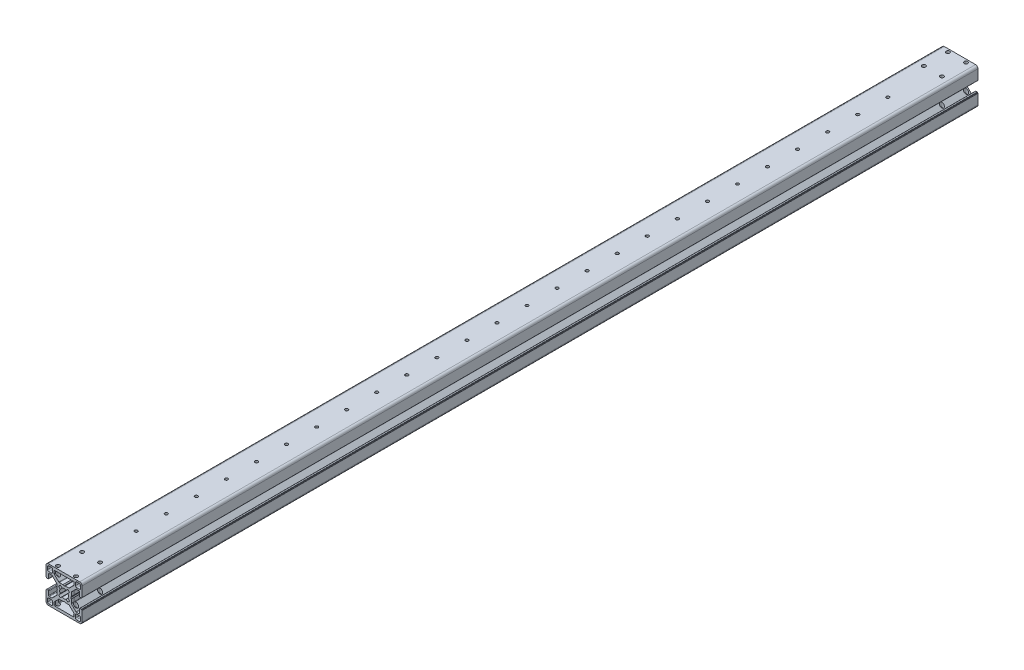
from build123d import *

# Parameters (mm, degrees)
AUFSATZ_LINEAR_AUSTRAGEN1_DEPTH = 745
LINEARES_MUSTER1_COUNT          = 14
LINEARES_MUSTER1_PITCH          = 25
LINEARES_MUSTER1_COL_COUNT      = 13
LINEARES_MUSTER1_COL_PITCH      = 25
F_3_0_3_DURCHMESSER_BOHRUNG1_D  = 3


with BuildPart() as part:
    # Skizze1 → Aufsatz-Linear austragen1 (new body)
    with BuildSketch(Plane.XY.offset(1000)):
        with BuildLine():
            Line((0, -30), (26.000000692, -30))
            ThreePointArc((26.000000692, -30), (27.41421401, -29.414213664), (28.000000346, -28.000000346))
            Line((28.000000346, -28.000000346), (28.000000346, -19.699999564))
            ThreePointArc((28.000000346, -19.699999564), (27.941421702, -19.558578208), (27.800000346, -19.499999564))
            Line((27.800000346, -19.499999564), (27.500000346, -19.499999564))
            Line((27.500000346, -19.499999564), (27.500000346, -19.200000374))
            ThreePointArc((27.500000346, -19.200000374), (27.441421593, -19.058578753), (27.299999973, -19))
            Line((27.299999973, -19), (26.29999991, -19))
            ThreePointArc((26.29999991, -19), (25.94644652, -19.146446609), (25.79999991, -19.5))
            Line((25.79999991, -19.5), (25.79999991, -22.75))
            ThreePointArc((25.79999991, -22.75), (25.653553301, -23.103553391), (25.29999991, -23.25))
            Line((25.29999991, -23.25), (23.257106692, -23.25))
            ThreePointArc((23.257106692, -23.25), (23.065764975, -23.211939766), (22.903553301, -23.103553391))
            Line((22.903553301, -23.103553391), (19.150912386, -19.350912475))
            ThreePointArc((19.150912386, -19.350912475), (19.04252601, -19.188700801), (19.004465776, -18.997359085))
            Line((19.004465776, -18.997359085), (19.004465776, -15.9535893))
            ThreePointArc((19.004465776, -15.9535893), (18.99765098, -15.901825632), (18.977671004, -15.853589554))
            Line((18.977671004, -15.853589554), (18.542587196, -15.099999747))
            ThreePointArc((18.542587196, -15.099999747), (18.515792423, -15), (18.542587196, -14.900000253))
            Line((18.542587196, -14.900000253), (18.977671004, -14.146410446))
            ThreePointArc((18.977671004, -14.146410446), (18.99765098, -14.098174367), (19.004465776, -14.0464107))
            Line((19.004465776, -14.0464107), (19.004465776, -11.002640915))
            ThreePointArc((19.004465776, -11.002640915), (19.04252601, -10.811299199), (19.150912386, -10.649087524))
            Line((19.150912386, -10.649087524), (22.903553301, -6.896446609))
            ThreePointArc((22.903553301, -6.896446609), (23.065764975, -6.788060234), (23.257106692, -6.75))
            Line((23.257106692, -6.75), (25.29999991, -6.75))
            ThreePointArc((25.29999991, -6.75), (25.653553301, -6.896446609), (25.79999991, -7.25))
            Line((25.79999991, -7.25), (25.79999991, -10.5))
            ThreePointArc((25.79999991, -10.5), (25.94644652, -10.853553391), (26.29999991, -11))
            Line((26.29999991, -11), (27.299999973, -11))
            ThreePointArc((27.299999973, -11), (27.441421593, -10.941421247), (27.500000346, -10.799999626))
            Line((27.500000346, -10.799999626), (27.500000346, -10.500000436))
            Line((27.500000346, -10.500000436), (27.800000346, -10.500000436))
            ThreePointArc((27.800000346, -10.500000436), (27.941421702, -10.441421792), (28.000000346, -10.300000436))
            Line((28.000000346, -10.300000436), (28.000000346, -1.999999654))
            ThreePointArc((28.000000346, -1.999999654), (27.41421401, -0.585786336), (26.000000692, 0))
            Line((26.000000692, 0), (0, 0))
            ThreePointArc((0, 0), (-1.414213318, -0.585786336), (-1.999999654, -1.999999654))
            Line((-1.999999654, -1.999999654), (-1.999999654, -10.300000436))
            ThreePointArc((-1.999999654, -10.300000436), (-1.94142101, -10.441421792), (-1.799999654, -10.500000436))
            Line((-1.799999654, -10.500000436), (-1.499999654, -10.500000436))
            Line((-1.499999654, -10.500000436), (-1.499999654, -10.799999626))
            ThreePointArc((-1.499999654, -10.799999626), (-1.441420901, -10.941421247), (-1.29999928, -11))
            Line((-1.29999928, -11), (-0.299999218, -11))
            ThreePointArc((-0.299999218, -11), (0.053554173, -10.853553391), (0.200000782, -10.5))
            Line((0.200000782, -10.5), (0.200000782, -7.25))
            ThreePointArc((0.200000782, -7.25), (0.346447391, -6.896446609), (0.700000782, -6.75))
            Line((0.700000782, -6.75), (2.742894001, -6.75))
            ThreePointArc((2.742894001, -6.75), (2.934235717, -6.788060234), (3.096447391, -6.896446609))
            Line((3.096447391, -6.896446609), (6.849088307, -10.649087524))
            ThreePointArc((6.849088307, -10.649087524), (6.957474682, -10.811299199), (6.995534916, -11.002640915))
            Line((6.995534916, -11.002640915), (6.995534916, -14.0464107))
            ThreePointArc((6.995534916, -14.0464107), (7.002349713, -14.098174368), (7.022329689, -14.146410446))
            Line((7.022329689, -14.146410446), (7.457413497, -14.900000253))
            ThreePointArc((7.457413497, -14.900000253), (7.484208269, -15), (7.457413497, -15.099999747))
            Line((7.457413497, -15.099999747), (7.022329689, -15.853589554))
            ThreePointArc((7.022329689, -15.853589554), (7.002349713, -15.901825632), (6.995534916, -15.9535893))
            Line((6.995534916, -15.9535893), (6.995534916, -18.997359085))
            ThreePointArc((6.995534916, -18.997359085), (6.957474682, -19.188700801), (6.849088307, -19.350912475))
            Line((6.849088307, -19.350912475), (3.096447391, -23.103553391))
            ThreePointArc((3.096447391, -23.103553391), (2.934235717, -23.211939766), (2.742894001, -23.25))
            Line((2.742894001, -23.25), (0.700000782, -23.25))
            ThreePointArc((0.700000782, -23.25), (0.346447391, -23.103553391), (0.200000782, -22.75))
            Line((0.200000782, -22.75), (0.200000782, -19.5))
            ThreePointArc((0.200000782, -19.5), (0.053554173, -19.146446609), (-0.299999218, -19))
            Line((-0.299999218, -19), (-1.29999928, -19))
            ThreePointArc((-1.29999928, -19), (-1.441420901, -19.058578753), (-1.499999654, -19.200000374))
            Line((-1.499999654, -19.200000374), (-1.499999654, -19.499999564))
            Line((-1.499999654, -19.499999564), (-1.799999273, -19.499999564))
            ThreePointArc((-1.799999273, -19.499999564), (-1.941420898, -19.558578319), (-1.999999654, -19.699999945))
            Line((-1.999999654, -19.699999945), (-1.999999654, -28.000000346))
            ThreePointArc((-1.999999654, -28.000000346), (-1.414213318, -29.414213664), (0, -30))
        make_face()
        with BuildLine():
            Line((2.500000029, -5.500000365), (0.299999247, -5.500000365))
            ThreePointArc((0.299999247, -5.500000365), (-0.407107528, -5.207107148), (-0.700000744, -4.500000374))
            Line((-0.700000744, -4.500000374), (-0.700000744, -2.299999592))
            ThreePointArc((-0.700000744, -2.299999592), (-0.407107528, -1.592892818), (0.299999247, -1.299999602))
            Line((0.299999247, -1.299999602), (2.500000029, -1.299999602))
            ThreePointArc((2.500000029, -1.299999602), (3.207106803, -1.592892818), (3.500000019, -2.299999592))
            Line((3.500000019, -2.299999592), (3.500000019, -4.500000374))
            ThreePointArc((3.500000019, -4.500000374), (3.207106803, -5.207107148), (2.500000029, -5.500000365))
        make_face(mode=Mode.SUBTRACT)
        with BuildLine():
            Line((3.500000019, -25.499999626), (3.500000019, -27.700000408))
            ThreePointArc((3.500000019, -27.700000408), (3.207106803, -28.407107182), (2.500000029, -28.700000398))
            Line((2.500000029, -28.700000398), (0.299999247, -28.700000398))
            ThreePointArc((0.299999247, -28.700000398), (-0.407107528, -28.407107182), (-0.700000744, -27.700000408))
            Line((-0.700000744, -27.700000408), (-0.700000744, -25.499999626))
            ThreePointArc((-0.700000744, -25.499999626), (-0.407107528, -24.792892851), (0.299999247, -24.499999635))
            Line((0.299999247, -24.499999635), (2.500000029, -24.499999635))
            ThreePointArc((2.500000029, -24.499999635), (3.207106803, -24.792892851), (3.500000019, -25.499999626))
        make_face(mode=Mode.SUBTRACT)
        with BuildLine():
            Line((23.500000664, -24.499999635), (25.700001446, -24.499999635))
            ThreePointArc((25.700001446, -24.499999635), (26.40710822, -24.792892851), (26.700001436, -25.499999626))
            Line((26.700001436, -25.499999626), (26.700001436, -27.700000408))
            ThreePointArc((26.700001436, -27.700000408), (26.40710822, -28.407107182), (25.700001446, -28.700000398))
            Line((25.700001446, -28.700000398), (23.500000664, -28.700000398))
            ThreePointArc((23.500000664, -28.700000398), (22.792893889, -28.407107182), (22.500000673, -27.700000408))
            Line((22.500000673, -27.700000408), (22.500000673, -25.499999626))
            ThreePointArc((22.500000673, -25.499999626), (22.792893889, -24.792892851), (23.500000664, -24.499999635))
        make_face(mode=Mode.SUBTRACT)
        with BuildLine():
            Line((22.500000673, -4.500000374), (22.500000673, -2.299999592))
            ThreePointArc((22.500000673, -2.299999592), (22.792893889, -1.592892818), (23.500000664, -1.299999602))
            Line((23.500000664, -1.299999602), (25.700001446, -1.299999602))
            ThreePointArc((25.700001446, -1.299999602), (26.40710822, -1.592892818), (26.700001436, -2.299999592))
            Line((26.700001436, -2.299999592), (26.700001436, -4.500000374))
            ThreePointArc((26.700001436, -4.500000374), (26.40710822, -5.207107148), (25.700001446, -5.500000365))
            Line((25.700001446, -5.500000365), (23.500000664, -5.500000365))
            ThreePointArc((23.500000664, -5.500000365), (22.792893889, -5.207107148), (22.500000673, -4.500000374))
        make_face(mode=Mode.SUBTRACT)
        with BuildLine():
            Line((16.135929758, -19.518400903), (14.60012987, -18.280561767))
            ThreePointArc((14.60012987, -18.280561767), (13.000000346, -18.65), (11.399870822, -18.280561767))
            Line((11.399870822, -18.280561767), (9.864070934, -19.518400903))
            ThreePointArc((9.864070934, -19.518400903), (9.118998087, -18.897155561), (8.494663454, -18.154669473))
            Line((8.494663454, -18.154669473), (9.719438615, -16.600129596))
            ThreePointArc((9.719438615, -16.600129596), (9.350000346, -15), (9.719438615, -13.399870403))
            Line((9.719438615, -13.399870403), (8.494663454, -11.845330527))
            ThreePointArc((8.494663454, -11.845330527), (9.118998087, -11.102844439), (9.864070934, -10.481599097))
            Line((9.864070934, -10.481599097), (11.399870822, -11.719438233))
            ThreePointArc((11.399870822, -11.719438233), (13.000000346, -11.35), (14.60012987, -11.719438233))
            Line((14.60012987, -11.719438233), (16.135929758, -10.481599097))
            ThreePointArc((16.135929758, -10.481599097), (16.881002606, -11.102844439), (17.505337239, -11.845330527))
            Line((17.505337239, -11.845330527), (16.280562078, -13.399870403))
            ThreePointArc((16.280562078, -13.399870403), (16.650000346, -15), (16.280562078, -16.600129596))
            Line((16.280562078, -16.600129596), (17.505337239, -18.154669473))
            ThreePointArc((17.505337239, -18.154669473), (16.881002606, -18.89715556), (16.135929758, -19.518400903))
        make_face(mode=Mode.SUBTRACT)
        with BuildLine():
            Line((17.350946534, -21.146641666), (21.103749013, -24.903586157))
            ThreePointArc((21.103749013, -24.903586157), (21.211993189, -25.065730174), (21.250000673, -25.256944491))
            Line((21.250000673, -25.256944491), (21.250000673, -27.299999237))
            ThreePointArc((21.250000673, -27.299999237), (21.103554064, -27.653552628), (20.750000673, -27.799999237))
            Line((20.750000673, -27.799999237), (5.250000019, -27.799999237))
            ThreePointArc((5.250000019, -27.799999237), (4.896446629, -27.653552628), (4.750000019, -27.299999237))
            Line((4.750000019, -27.299999237), (4.750000019, -25.256944491))
            ThreePointArc((4.750000019, -25.256944491), (4.788007503, -25.065730174), (4.896251679, -24.903586157))
            Line((4.896251679, -24.903586157), (8.649054159, -21.146641666))
            ThreePointArc((8.649054159, -21.146641666), (8.811333398, -21.038113019), (9.002802498, -21))
            Line((9.002802498, -21), (12.046810201, -21))
            ThreePointArc((12.046810201, -21), (12.098213578, -20.993281383), (12.146163358, -20.973576929))
            Line((12.146163358, -20.973576929), (12.900647189, -20.541720281))
            ThreePointArc((12.900647189, -20.541720281), (13.000000346, -20.51529721), (13.099353503, -20.541720281))
            Line((13.099353503, -20.541720281), (13.853837334, -20.973576929))
            ThreePointArc((13.853837334, -20.973576929), (13.901787115, -20.993281383), (13.953190491, -21))
            Line((13.953190491, -21), (16.997198194, -21))
            ThreePointArc((16.997198194, -21), (17.188667295, -21.038113019), (17.350946534, -21.146641666))
        make_face(mode=Mode.SUBTRACT)
        with BuildLine():
            Line((16.997198194, -9), (13.953190491, -9))
            ThreePointArc((13.953190491, -9), (13.901787115, -9.006718617), (13.853837334, -9.026423071))
            Line((13.853837334, -9.026423071), (13.099353503, -9.458279719))
            ThreePointArc((13.099353503, -9.458279719), (13.000000346, -9.48470279), (12.900647189, -9.458279719))
            Line((12.900647189, -9.458279719), (12.146163358, -9.026423071))
            ThreePointArc((12.146163358, -9.026423071), (12.098213578, -9.006718617), (12.046810201, -9))
            Line((12.046810201, -9), (9.002802498, -9))
            ThreePointArc((9.002802498, -9), (8.811333398, -8.961886981), (8.649054159, -8.853358334))
            Line((8.649054159, -8.853358334), (4.896251679, -5.096413843))
            ThreePointArc((4.896251679, -5.096413843), (4.788007503, -4.934269826), (4.750000019, -4.743055509))
            Line((4.750000019, -4.743055509), (4.750000019, -2.700000763))
            ThreePointArc((4.750000019, -2.700000763), (4.896446629, -2.346447372), (5.250000019, -2.200000763))
            Line((5.250000019, -2.200000763), (20.750000673, -2.200000763))
            ThreePointArc((20.750000673, -2.200000763), (21.103554064, -2.346447372), (21.250000673, -2.700000763))
            Line((21.250000673, -2.700000763), (21.250000673, -4.743055509))
            ThreePointArc((21.250000673, -4.743055509), (21.211993189, -4.934269826), (21.103749013, -5.096413843))
            Line((21.103749013, -5.096413843), (17.350946534, -8.853358334))
            ThreePointArc((17.350946534, -8.853358334), (17.188667295, -8.961886981), (16.997198194, -9))
        make_face(mode=Mode.SUBTRACT)
    extrude(amount=-AUFSATZ_LINEAR_AUSTRAGEN1_DEPTH)

    # Skizze2 → M3 Gewindebohrung1 (revolve, cut)
    with BuildSketch(Plane(origin=(13, 0, 640), x_dir=(0, 0, 1), z_dir=(1, 0, 0))):
        Polygon((0, 0), (0, 30), (1.525, 30), (1.25, 29.725), (1.25, 0), align=None)
    m3_gewindebohrung1 = revolve(axis=Axis((13, 6.35, 640), (0, -1, 0)), mode=Mode.SUBTRACT)

    # Lineares Muster1: M3 Gewindebohrung1 ×14
    with Locations(*[(0, 0, -i * LINEARES_MUSTER1_PITCH) for i in range(1, LINEARES_MUSTER1_COUNT)]):
        add(m3_gewindebohrung1, mode=Mode.SUBTRACT)

    # Lineares Muster1 col: M3 Gewindebohrung1 ×13
    with Locations(*[(0, 0, i * LINEARES_MUSTER1_COL_PITCH) for i in range(1, LINEARES_MUSTER1_COL_COUNT)]):
        add(m3_gewindebohrung1, mode=Mode.SUBTRACT)

    # Ø3.0 (3) Durchmesser Bohrung1 (through all)
    with Locations(Plane(origin=(0, 0, 0), x_dir=(1, 0, 0), z_dir=(0, 1, 0))):
        with Locations((5.500000346, -277.5), (5.500000346, -257.5), (20.500000346, -277.5), (20.500000346, -257.5), (20.500000346, -997.5), (20.500000346, -977.5), (5.500000346, -997.5), (5.500000346, -977.5)):
            Hole(F_3_0_3_DURCHMESSER_BOHRUNG1_D / 2)


solid = part.part
